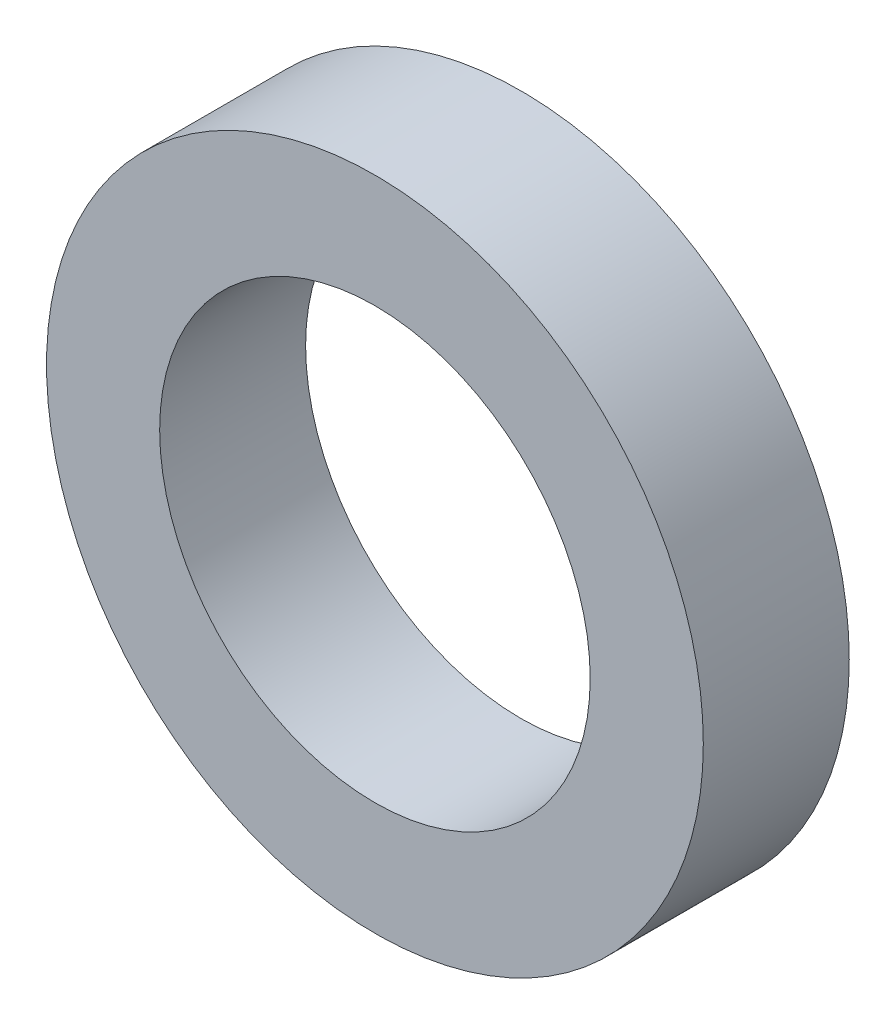
from build123d import *

# Parameters (mm, degrees)
MODEL_R             = 4.5
MODEL_R_2           = 2.95
BOSS_EXTRUDE1_DEPTH = 2


with BuildPart() as part:
    # Model → Boss-Extrude1 (new body)
    with BuildSketch(Plane.XY):
        with Locations((-45, -4)):
            Circle(MODEL_R)
        with Locations((-45, -4)):
            Circle(MODEL_R_2, mode=Mode.SUBTRACT)
    extrude(amount=BOSS_EXTRUDE1_DEPTH)


solid = part.part
